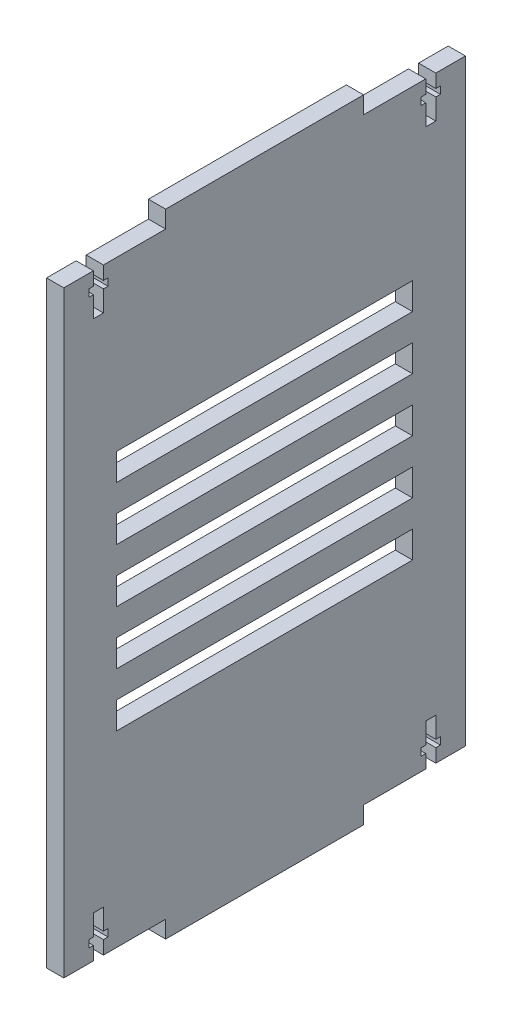
from build123d import *

# Parameters (mm, degrees)
SKETCH1_W           = 119.48
SKETCH1_H           = 177.8
BOSS_EXTRUDE1_DEPTH = 5.13
CUT_EXTRUDE1_DEPTH  = 5.13
SKETCH3_W           = 88
SKETCH3_H           = 8
VENTS_DEPTH         = 5.13
VENTS_PATTERN_COUNT = 5
VENTS_PATTERN_PITCH = 16
SKETCH4_W           = 5.13
SKETCH4_H           = 58.88
BOSS_EXTRUDE2_DEPTH = 5.13
SKETCH5_W           = 5.13
SKETCH5_H           = 58.88
BOSS_EXTRUDE3_DEPTH = 5.13


with BuildPart() as part:
    # Sketch1 → Boss-Extrude1 (new body)
    with BuildSketch(Plane(origin=(0, 0, 0), x_dir=(0, 0, -1), z_dir=(1, 0, 0))):
        with Locations((24.047197546, -50.943101868)):
            Rectangle(SKETCH1_W, SKETCH1_H)
    extrude(amount=BOSS_EXTRUDE1_DEPTH)

    # Sketch2 → Cut-Extrude1 (cut)
    with BuildSketch(Plane(origin=(5.13, 0, 0), x_dir=(0, 0, -1), z_dir=(1, 0, 0))):
        Polygon((-26.892802454, 37.956898132), (-23.895802454, 37.956898132), (-23.895802454, 33.961898132), (-22.536802454, 33.961898132), (-22.536802454, 31.794898132), (-23.895802454, 31.794898132), (-23.895802454, 25.587898132), (-26.892802454, 25.587898132), (-26.892802454, 31.794898132), (-28.251802454, 31.794898132), (-28.251802454, 33.961898132), (-26.892802454, 33.961898132), align=None)
        Polygon((71.987197546, 33.961898132), (71.987197546, 37.956898132), (74.984197546, 37.956898132), (74.984197546, 33.961898132), (76.343197546, 33.961898132), (76.343197546, 31.794898132), (74.984197546, 31.794898132), (74.984197546, 25.587898132), (71.987197546, 25.587898132), (71.987197546, 31.794898132), (70.628197546, 31.794898132), (70.628197546, 33.961898132), align=None)
        Polygon((76.343197546, -133.681101868), (74.984197546, -133.681101868), (74.984197546, -127.474101868), (71.987197546, -127.474101868), (71.987197546, -133.681101868), (70.628197546, -133.681101868), (70.628197546, -135.848101868), (71.987197546, -135.848101868), (71.987197546, -139.843101868), (74.984197546, -139.843101868), (74.984197546, -135.848101868), (76.343197546, -135.848101868), align=None)
        Polygon((-26.892802454, -139.843101868), (-23.895802454, -139.843101868), (-23.895802454, -135.848101868), (-22.536802454, -135.848101868), (-22.536802454, -133.681101868), (-23.895802454, -133.681101868), (-23.895802454, -127.474101868), (-26.892802454, -127.474101868), (-26.892802454, -133.681101868), (-28.251802454, -133.681101868), (-28.251802454, -135.848101868), (-26.892802454, -135.848101868), align=None)
    extrude(amount=-CUT_EXTRUDE1_DEPTH, mode=Mode.SUBTRACT)

    # Sketch3 → Vents (cut)
    with BuildSketch(Plane.ZY):
        with Locations((-24.047197546, -16.043101868)):
            Rectangle(SKETCH3_W, SKETCH3_H)
    vents = extrude(amount=-VENTS_DEPTH, mode=Mode.SUBTRACT)

    # Vents pattern: Vents ×5
    with Locations(*[(0, -i * VENTS_PATTERN_PITCH, 0) for i in range(1, VENTS_PATTERN_COUNT)]):
        add(vents, mode=Mode.SUBTRACT)

    # Sketch4 → Boss-Extrude2 (add)
    with BuildSketch(Plane(origin=(0, 37.956898132, 0), x_dir=(1, 0, 0), z_dir=(0, 1, 0))):
        with Locations((2.565, 24.047197546)):
            Rectangle(SKETCH4_W, SKETCH4_H)
    extrude(amount=BOSS_EXTRUDE2_DEPTH)

    # Sketch5 → Boss-Extrude3 (add)
    with BuildSketch(Plane.XZ.offset(139.843101868)):
        with Locations((2.565, -24.047197546)):
            Rectangle(SKETCH5_W, SKETCH5_H)
    extrude(amount=BOSS_EXTRUDE3_DEPTH)


solid = part.part
